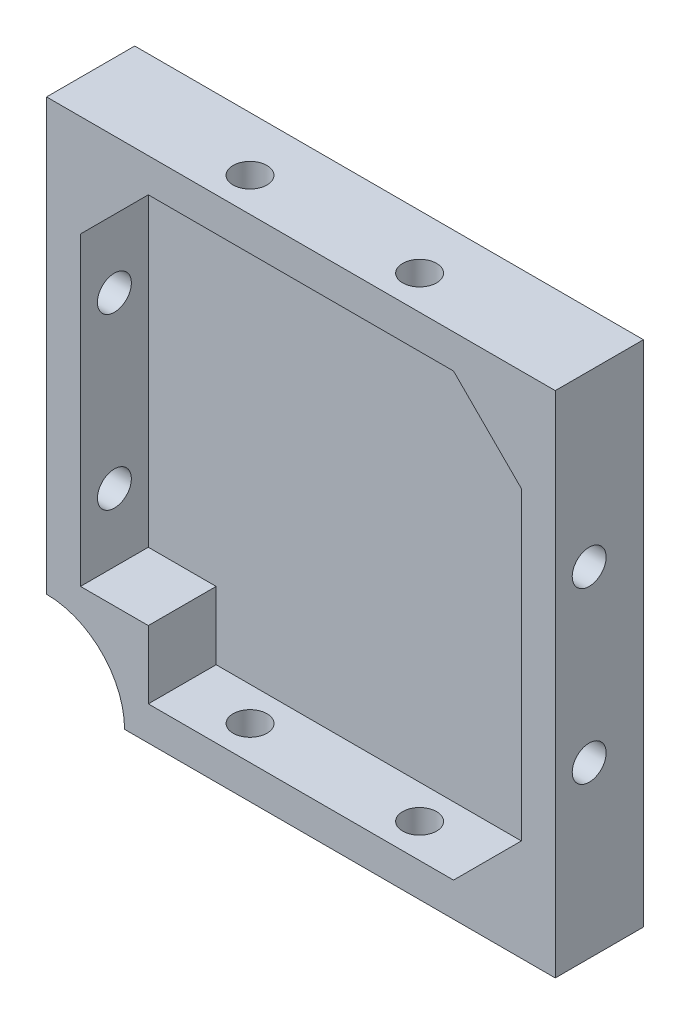
from build123d import *

# Parameters (mm, degrees)
BOSS_EXTRU_1_DEPTH        = 13
COQUE1_T                  = -5
COQUE1_THICKNESS_2_FACE_W = 65
COQUE1_THICKNESS_2_FACE_H = 65
COQUE1_THICKNESS_2_DEPTH  = 2
ENL_V_MAT_EXTRU_1_REACH   = 88.587
ESQUISSE2_R               = 2.5
ENL_V_MAT_EXTRU_2_REACH   = 95.396
ESQUISSE3_R               = 2.5
ESQUISSE4_W               = 15
ESQUISSE4_H               = 15
BOSS_EXTRU_2_DEPTH        = 10
ESQUISSE5_R               = 11.5
ENL_V_MAT_EXTRU_3_DEPTH   = 13


with BuildPart() as part:
    # Esquisse1 → Boss.-Extru.1 (new body)
    with BuildSketch(Plane.XY):
        Polygon((44.118436308, 33.728448276), (54.118436308, 33.728448276), (54.118436308, 23.728448276), (54.118436308, -41.271551724), (-20.881563692, -41.271551724), (-20.881563692, 33.728448276), align=None)
    extrude(amount=BOSS_EXTRU_1_DEPTH)

    # Coque1
    coque1_openings = [part.faces().sort_by_distance(p)[0] for p in [
        (16.618436308, -3.771551724, 13),
    ]]
    offset(amount=COQUE1_T, openings=coque1_openings, kind=Kind.INTERSECTION)

    # Coque1 thickness 2 face (on inner face of the shell) → Coque1 thickness 2 (cut)
    with BuildSketch(Plane(origin=(16.618436308, -3.771551724, 5), x_dir=(-1, 0, 0), z_dir=(0, 0, -1))):
        Rectangle(COQUE1_THICKNESS_2_FACE_W, COQUE1_THICKNESS_2_FACE_H)
    extrude(amount=COQUE1_THICKNESS_2_DEPTH, mode=Mode.SUBTRACT)

    # Enlèv. mat.-Extru.1: up to this face of the body (flat: up to its plane)
    enl_v_mat_extru_1_end = Plane(part.part.faces().sort_by_distance((54.118436308, -3.771551724, 6.5))[0])
    # Esquisse2 → Enlèv. mat.-Extru.1 (cut, up to the picked face)
    with BuildSketch(Plane.ZY.offset(20.881563692), mode=Mode.PRIVATE) as enl_v_mat_extru_1_sk1:
        with Locations(Location((8, -16.271551724, 0), (0, 0, 270))):
            Circle(ESQUISSE2_R)
    enl_v_mat_extru_1_tool1 = split(extrude(enl_v_mat_extru_1_sk1.sketch, amount=-ENL_V_MAT_EXTRU_1_REACH, mode=Mode.PRIVATE), bisect_by=enl_v_mat_extru_1_end, keep=Keep.BOTH, mode=Mode.PRIVATE)
    # Esquisse2 → Enlèv. mat.-Extru.1 (cut, up to the picked face)
    with BuildSketch(Plane.ZY.offset(20.881563692), mode=Mode.PRIVATE) as enl_v_mat_extru_1_sk2:
        with Locations(Location((8, 8.728448276, 0), (0, 0, 270))):
            Circle(ESQUISSE2_R)
    enl_v_mat_extru_1_tool2 = split(extrude(enl_v_mat_extru_1_sk2.sketch, amount=-ENL_V_MAT_EXTRU_1_REACH, mode=Mode.PRIVATE), bisect_by=enl_v_mat_extru_1_end, keep=Keep.BOTH, mode=Mode.PRIVATE)
    add(enl_v_mat_extru_1_tool1.solids().sort_by(Axis((-20.881564, -16.271552, 8), (1, 0, 0)))[0], mode=Mode.SUBTRACT)
    add(enl_v_mat_extru_1_tool2.solids().sort_by(Axis((-20.881564, 8.728448, 8), (1, 0, 0)))[0], mode=Mode.SUBTRACT)

    # Enlèv. mat.-Extru.2: up to this face of the body (flat: up to its plane)
    enl_v_mat_extru_2_end = Plane(part.part.faces().sort_by_distance((16.618436308, 33.728448276, 6.5))[0])
    # Esquisse3 → Enlèv. mat.-Extru.2 (cut, up to the picked face)
    with BuildSketch(Plane.XZ.offset(41.271551724), mode=Mode.PRIVATE) as enl_v_mat_extru_2_sk1:
        with Locations(Location((4.118436308, 8, 0), (0, 0, 270))):
            Circle(ESQUISSE3_R)
    enl_v_mat_extru_2_tool1 = split(extrude(enl_v_mat_extru_2_sk1.sketch, amount=-ENL_V_MAT_EXTRU_2_REACH, mode=Mode.PRIVATE), bisect_by=enl_v_mat_extru_2_end, keep=Keep.BOTH, mode=Mode.PRIVATE)
    # Esquisse3 → Enlèv. mat.-Extru.2 (cut, up to the picked face)
    with BuildSketch(Plane.XZ.offset(41.271551724), mode=Mode.PRIVATE) as enl_v_mat_extru_2_sk2:
        with Locations(Location((29.118436308, 8, 0), (0, 0, 270))):
            Circle(ESQUISSE3_R)
    enl_v_mat_extru_2_tool2 = split(extrude(enl_v_mat_extru_2_sk2.sketch, amount=-ENL_V_MAT_EXTRU_2_REACH, mode=Mode.PRIVATE), bisect_by=enl_v_mat_extru_2_end, keep=Keep.BOTH, mode=Mode.PRIVATE)
    add(enl_v_mat_extru_2_tool1.solids().sort_by(Axis((4.118436, -41.271552, 8), (0, 1, 0)))[0], mode=Mode.SUBTRACT)
    add(enl_v_mat_extru_2_tool2.solids().sort_by(Axis((29.118436, -41.271552, 8), (0, 1, 0)))[0], mode=Mode.SUBTRACT)

    # Esquisse4 → Boss.-Extru.2 (add)
    with BuildSketch(Plane.XY.offset(3)):
        Polygon((-5.881563692, 28.728448276), (-15.881563692, 18.728448276), (-15.881563692, 28.728448276), align=None)
        Polygon((49.118436308, 28.728448276), (49.118436308, 18.728448276), (39.118436308, 28.728448276), align=None)
        Polygon((49.118436308, -36.271551724), (49.118436308, -26.271551724), (39.118436308, -36.271551724), align=None)
        with Locations((-13.381563692, -33.771551724)):
            Rectangle(ESQUISSE4_W, ESQUISSE4_H)
    extrude(amount=BOSS_EXTRU_2_DEPTH)

    # Esquisse5 → Enlèv. mat.-Extru.3 (cut)
    with BuildSketch(Plane.XY.offset(13)):
        with Locations((-20.881563692, -41.271551724)):
            Circle(ESQUISSE5_R)
    extrude(amount=-ENL_V_MAT_EXTRU_3_DEPTH, mode=Mode.SUBTRACT)


solid = part.part
